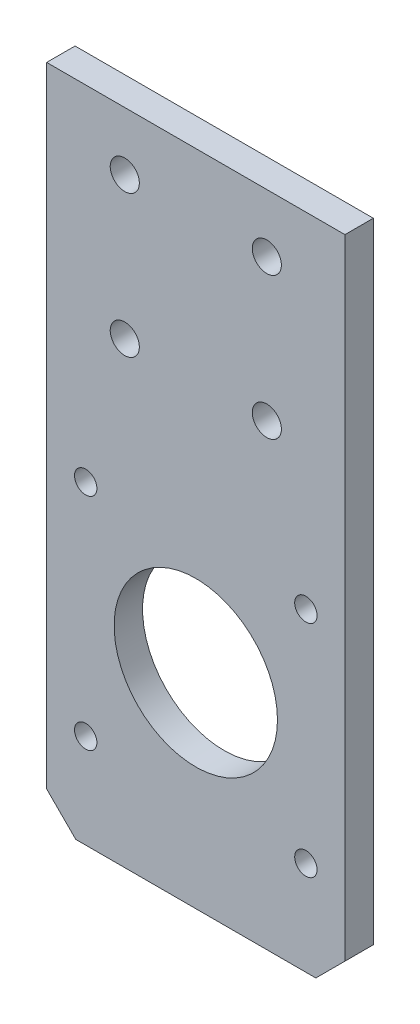
from build123d import *

# Parameters (mm, degrees)
CROQUIS1_W              = 42
CROQUIS1_H              = 85
CROQUIS1_R              = 2.05
CROQUIS1_R_2            = 2.55
SALIENTE_EXTRUIR1_DEPTH = 4
CROQUIS5_R              = 11.5
CROQUIS5_R_2            = 1.575
CORTAR_EXTRUIR2_DEPTH   = 5
CROQUIS7_W              = 42
CROQUIS7_H              = 7.7
SALIENTE_EXTRUIR2_DEPTH = 4
CHAFL_N1_SIZE           = 4.1


with BuildPart() as part:
    # Croquis1 → Saliente-Extruir1 (new body)
    with BuildSketch(Plane.XY):
        with Locations((21, 42.5)):
            Rectangle(CROQUIS1_W, CROQUIS1_H)
        with Locations((11, 76.8)):
            Circle(CROQUIS1_R, mode=Mode.SUBTRACT)
        with Locations((31, 76.8)):
            Circle(CROQUIS1_R, mode=Mode.SUBTRACT)
        with Locations((31, 56.8)):
            Circle(CROQUIS1_R, mode=Mode.SUBTRACT)
        with Locations((11, 56.8)):
            Circle(CROQUIS1_R, mode=Mode.SUBTRACT)
        with Locations((21, 21.08)):
            Circle(CROQUIS1_R_2, mode=Mode.SUBTRACT)
    extrude(amount=SALIENTE_EXTRUIR1_DEPTH)

    # Croquis5 → Cortar-Extruir2 (cut, through all)
    with BuildSketch(Plane.XY.offset(4)):
        with Locations((21, 21.08)):
            Circle(CROQUIS5_R)
        with Locations((5.5, 36.58)):
            Circle(CROQUIS5_R_2)
        with Locations((36.5, 36.58)):
            Circle(CROQUIS5_R_2)
        with Locations((36.5, 5.58)):
            Circle(CROQUIS5_R_2)
        with Locations((5.5, 5.58)):
            Circle(CROQUIS5_R_2)
    extrude(amount=-CORTAR_EXTRUIR2_DEPTH, mode=Mode.SUBTRACT)

    # Croquis7 → Saliente-Extruir2 (add, through all)
    with BuildSketch(Plane.XY.offset(4)):
        with Locations((21, -3.85)):
            Rectangle(CROQUIS7_W, CROQUIS7_H)
    extrude(amount=-SALIENTE_EXTRUIR2_DEPTH)

    # Chaflán1
    chafl_n1_edges = [part.edges().sort_by_distance(p)[0] for p in [
        (0, -7.7, 2),
        (42, -7.7, 2),
    ]]
    chamfer(chafl_n1_edges, length=CHAFL_N1_SIZE)


solid = part.part
